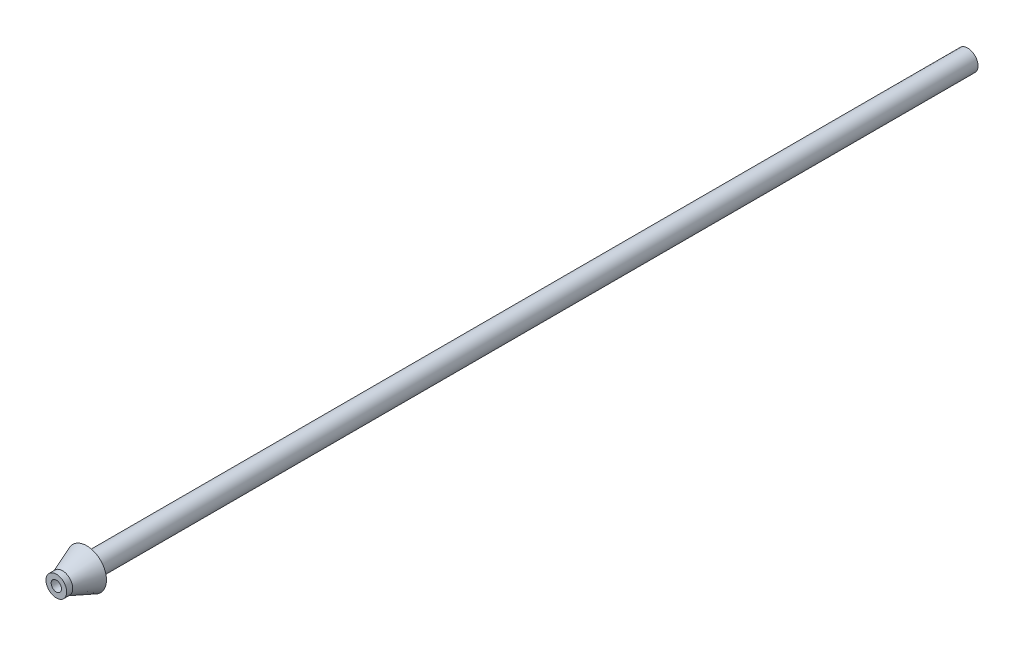
from build123d import *

# Parameters (mm, degrees)
SKETCH1_R           = 1.7
SKETCH1_R_2         = 0.85
BOSS_EXTRUDE1_DEPTH = 150


with BuildPart() as part:
    # Sketch1 → Boss-Extrude1 (new body)
    with BuildSketch(Plane.XY):
        Circle(SKETCH1_R)
        Circle(SKETCH1_R_2, mode=Mode.SUBTRACT)
    extrude(amount=BOSS_EXTRUDE1_DEPTH)

    # Sketch3 → Revolve1 (revolve)
    with BuildSketch(Plane(origin=(0, 0, 0), x_dir=(0, 0, -1), z_dir=(1, 0, 0))):
        Polygon((-149, 1.7), (-145, 3.25), (-145, 1.7), align=None)
    revolve(axis=Axis((0, 0, 150), (0, 0, -1)))


solid = part.part
